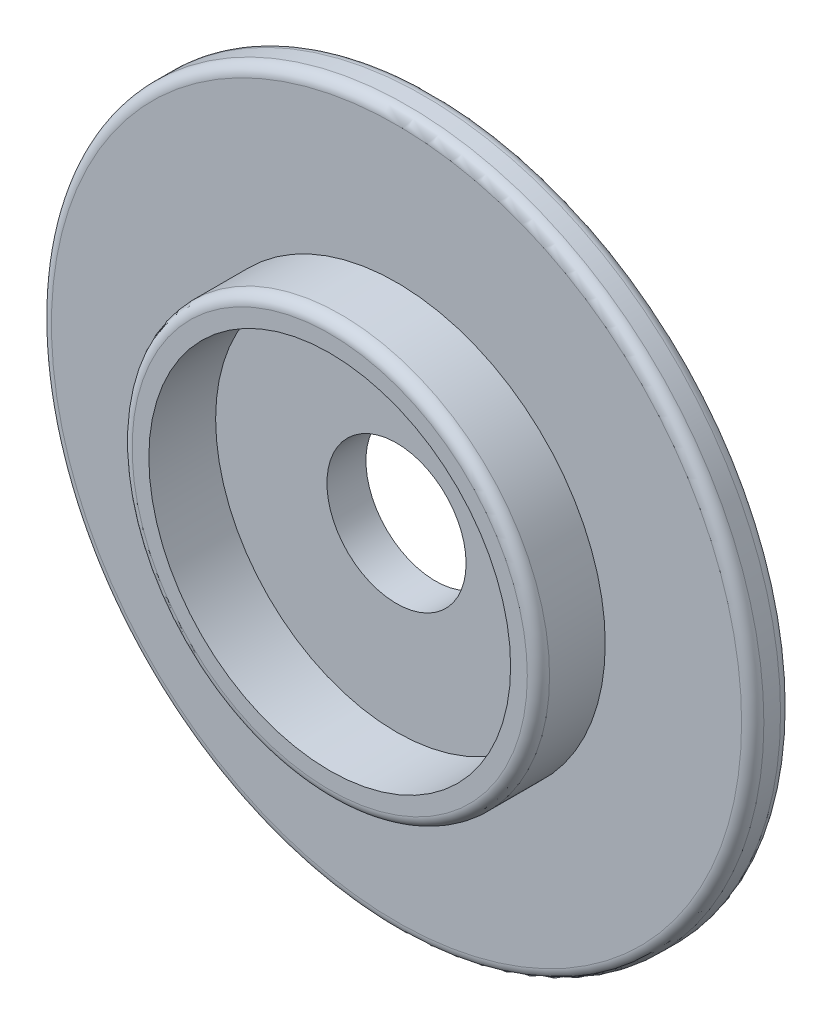
from build123d import *

# Parameters (mm, degrees)
SKETCH1_R           = 64
BOSS_EXTRUDE2_DEPTH = 7
SKETCH3_R           = 37.5
SKETCH3_R_2         = 32.5
BOSS_EXTRUDE3_DEPTH = 12
SKETCH6_R           = 12.5
CUT_EXTRUDE1_DEPTH  = 8
FILLET1_R           = 2


with BuildPart() as part:
    # Sketch1 → Boss-Extrude2 (new body)
    with BuildSketch(Plane.XY):
        Circle(SKETCH1_R)
    extrude(amount=BOSS_EXTRUDE2_DEPTH)

    # Sketch3 → Boss-Extrude3 (add)
    with BuildSketch(Plane.XY.offset(7)):
        Circle(SKETCH3_R)
        Circle(SKETCH3_R_2, mode=Mode.SUBTRACT)
    extrude(amount=BOSS_EXTRUDE3_DEPTH)

    # Sketch6 → Cut-Extrude1 (cut, through all)
    with BuildSketch(Plane.XY.offset(7)):
        Circle(SKETCH6_R)
    extrude(amount=-CUT_EXTRUDE1_DEPTH, mode=Mode.SUBTRACT)

    # Fillet1
    fillet1_edges = [part.edges().sort_by_distance(p)[0] for p in [
        (-64, 0, 0),
        (-64, 0, 7),
        (-37.5, 0, 19),
    ]]
    fillet(fillet1_edges, radius=FILLET1_R)


solid = part.part
